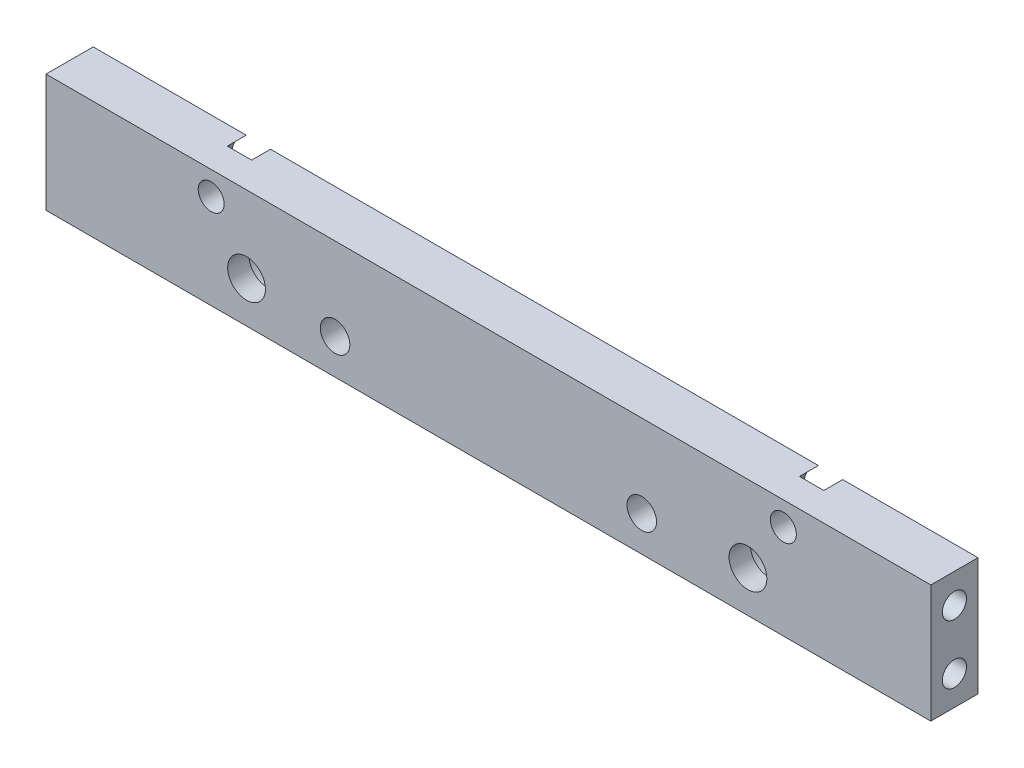
from build123d import *

# Parameters (mm, degrees)
SKETCH1_W                                        = 75
SKETCH1_H                                        = 10
BOSS_EXTRUDE1_DEPTH                              = 4
F_2_5_2_5_DIAMETER_HOLE1_D                       = 2.5
F_2_5_2_5_DIAMETER_HOLE1_DEPTH                   = 4
CBORE_FOR_M3_HEX_HEAD_MACHINE_SCREW1_D           = 3.2
CBORE_FOR_M3_HEX_HEAD_MACHINE_SCREW1_DEPTH       = 4
CBORE_FOR_M3_HEX_HEAD_MACHINE_SCREW1_CBORE_D     = 5.8
CBORE_FOR_M3_HEX_HEAD_MACHINE_SCREW1_CBORE_DEPTH = 2.2
CBORE_FOR_M2_HEX_HEAD_MACHINE_SCREW1_D           = 2.2
CBORE_FOR_M2_HEX_HEAD_MACHINE_SCREW1_DEPTH       = 4
CBORE_FOR_M2_HEX_HEAD_MACHINE_SCREW1_CBORE_D     = 4.499999997
CBORE_FOR_M2_HEX_HEAD_MACHINE_SCREW1_CBORE_DEPTH = 1.6
F_2_05_2_05_DIAMETER_HOLE1_D                     = 2.05
F_2_05_2_05_DIAMETER_HOLE1_DEPTH                 = 8
F_2_05_2_05_DIAMETER_HOLE1_TIP                   = 0.615882135
F_2_05_2_05_DIAMETER_HOLE2_D                     = 2.05
F_2_05_2_05_DIAMETER_HOLE2_DEPTH                 = 8
F_2_05_2_05_DIAMETER_HOLE2_TIP                   = 0.615882135


with BuildPart() as part:
    # Sketch1 → Boss-Extrude1 (new body)
    with BuildSketch(Plane.XY.offset(4)):
        Rectangle(SKETCH1_W, SKETCH1_H)
    extrude(amount=-BOSS_EXTRUDE1_DEPTH)

    # Ø2.5 (2.5) Diameter Hole1
    with Locations(Plane(origin=(0, 0, 0), x_dir=(-1, 0, 0), z_dir=(0, 0, -1))):
        with Locations((-13, -2), (13, -2)):
            Hole(F_2_5_2_5_DIAMETER_HOLE1_D / 2, depth=F_2_5_2_5_DIAMETER_HOLE1_DEPTH)

    # CBORE for M3 Hex Head Machine Screw1
    with Locations(Plane(origin=(0, 0, 0), x_dir=(-1, 0, 0), z_dir=(0, 0, -1))):
        with Locations((-22, -1.5), (20.5, -1.5)):
            CounterBoreHole(CBORE_FOR_M3_HEX_HEAD_MACHINE_SCREW1_D / 2, CBORE_FOR_M3_HEX_HEAD_MACHINE_SCREW1_CBORE_D / 2, CBORE_FOR_M3_HEX_HEAD_MACHINE_SCREW1_CBORE_DEPTH, depth=CBORE_FOR_M3_HEX_HEAD_MACHINE_SCREW1_DEPTH)

    # CBORE for M2 Hex Head Machine Screw1
    with Locations(Plane(origin=(0, 0, 0), x_dir=(-1, 0, 0), z_dir=(0, 0, -1))):
        with Locations((23.5, 3), (-25, 3)):
            CounterBoreHole(CBORE_FOR_M2_HEX_HEAD_MACHINE_SCREW1_D / 2, CBORE_FOR_M2_HEX_HEAD_MACHINE_SCREW1_CBORE_D / 2, CBORE_FOR_M2_HEX_HEAD_MACHINE_SCREW1_CBORE_DEPTH, depth=CBORE_FOR_M2_HEX_HEAD_MACHINE_SCREW1_DEPTH)

    # Ø2.05 (2.05) Diameter Hole1
    with Locations(Plane(origin=(37.5, 0, 0), x_dir=(0, 0, -1), z_dir=(1, 0, 0))):
        with Locations((-2, 2.5), (-2, -2.5)):
            Hole(F_2_05_2_05_DIAMETER_HOLE1_D / 2, depth=F_2_05_2_05_DIAMETER_HOLE1_DEPTH)
            with Locations((0, 0, -(F_2_05_2_05_DIAMETER_HOLE1_DEPTH + F_2_05_2_05_DIAMETER_HOLE1_TIP / 2))):  # 118° drill point
                Cone(0, F_2_05_2_05_DIAMETER_HOLE1_D / 2, F_2_05_2_05_DIAMETER_HOLE1_TIP, mode=Mode.SUBTRACT)

    # Ø2.05 (2.05) Diameter Hole2
    with Locations(Plane.ZY.offset(37.5)):
        with Locations((2, -2.5), (2, 2.5)):
            Hole(F_2_05_2_05_DIAMETER_HOLE2_D / 2, depth=F_2_05_2_05_DIAMETER_HOLE2_DEPTH)
            with Locations((0, 0, -(F_2_05_2_05_DIAMETER_HOLE2_DEPTH + F_2_05_2_05_DIAMETER_HOLE2_TIP / 2))):  # 118° drill point
                Cone(0, F_2_05_2_05_DIAMETER_HOLE2_D / 2, F_2_05_2_05_DIAMETER_HOLE2_TIP, mode=Mode.SUBTRACT)


solid = part.part
